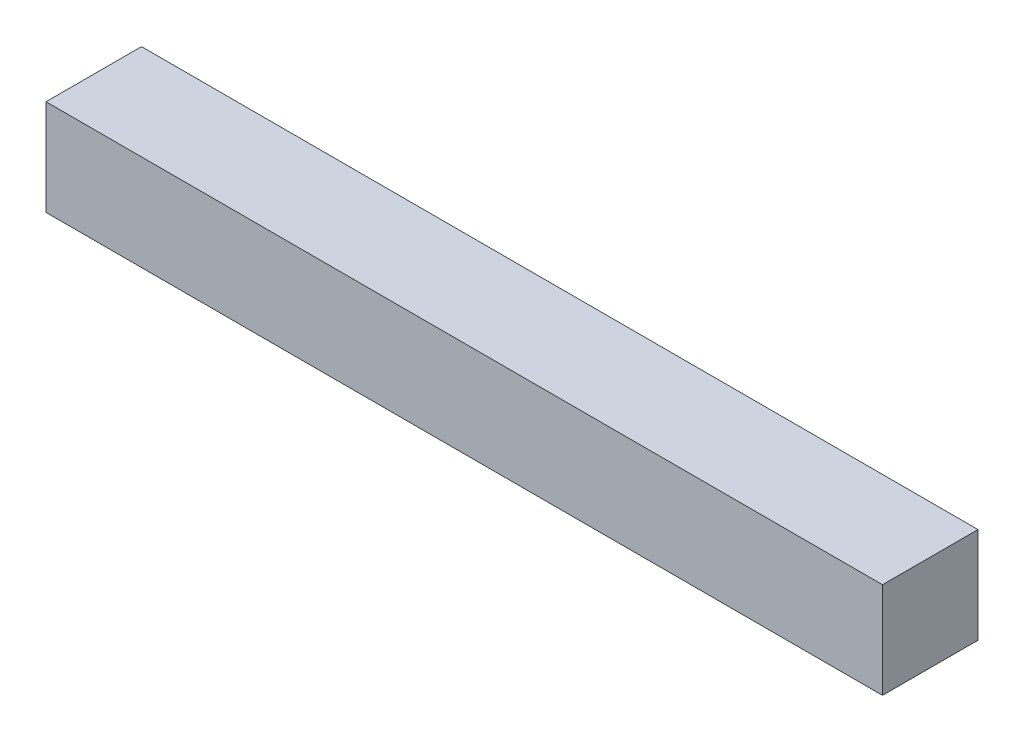
from build123d import *

# Parameters (mm, degrees)
SKETCH2_W           = 34.798
SKETCH2_H           = 34.925
BOSS_EXTRUDE1_DEPTH = 304.8


with BuildPart() as part:
    # Sketch2 → Boss-Extrude1 (new body)
    with BuildSketch(Plane(origin=(0, 0, 0), x_dir=(0, 0, -1), z_dir=(1, 0, 0))):
        with Locations((17.399, 17.4625)):
            Rectangle(SKETCH2_W, SKETCH2_H)
    extrude(amount=BOSS_EXTRUDE1_DEPTH)


solid = part.part
